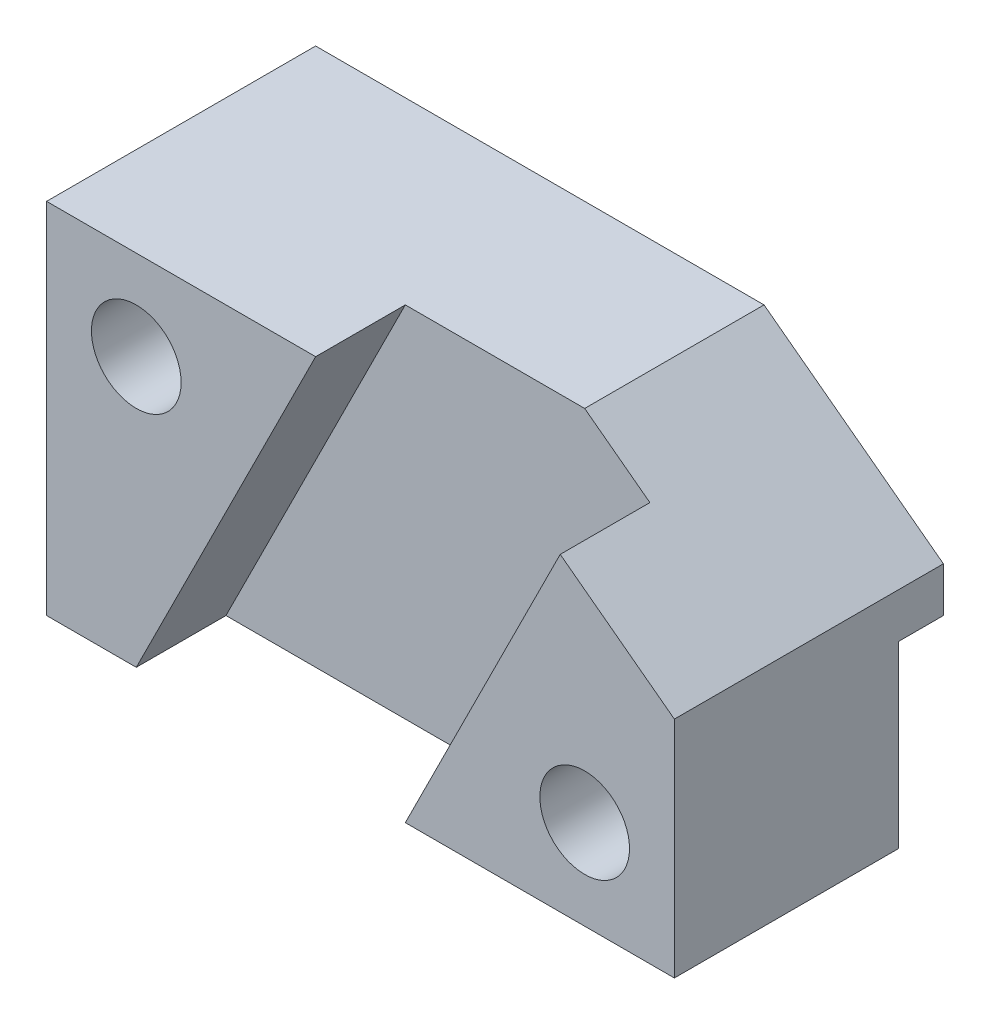
from build123d import *

# Parameters (mm, degrees)
SKETCH1_W               = 70
SKETCH1_H               = 30
BOSS_EXTRUDE1_DEPTH     = 40
CUT_EXTRUDE1_DEPTH      = 10
CUT_EXTRUDE2_DEPTH      = 1
CUT_EXTRUDE2_DEPTH_BACK = 31
SKETCH4_W               = 5
SKETCH4_H               = 20
CUT_EXTRUDE3_DEPTH      = 71
SKETCH5_R               = 5
CUT_EXTRUDE4_DEPTH      = 31
SKETCH6_R               = 5
CUT_EXTRUDE5_DEPTH      = 31


with BuildPart() as part:
    # Sketch1 → Boss-Extrude1 (new body)
    with BuildSketch(Plane(origin=(0, 0, 0), x_dir=(1, 0, 0), z_dir=(0, 1, 0))):
        with Locations((35, 15)):
            Rectangle(SKETCH1_W, SKETCH1_H)
    extrude(amount=BOSS_EXTRUDE1_DEPTH)

    # Sketch2 → Cut-Extrude1 (cut)
    with BuildSketch(Plane.XY):
        Polygon((30, 40), (10, 0), (40, 0), (60, 40), align=None)
    extrude(amount=-CUT_EXTRUDE1_DEPTH, mode=Mode.SUBTRACT)

    # Sketch3 → Cut-Extrude2 (cut, two sides)
    with BuildSketch(Plane(origin=(0, 0, -30), x_dir=(-1, 0, 0), z_dir=(0, 0, -1))) as cut_extrude2_sk:
        Polygon((-70, 40), (-70, 25), (-50, 40), align=None)
    extrude(amount=CUT_EXTRUDE2_DEPTH, mode=Mode.SUBTRACT)
    extrude(cut_extrude2_sk.sketch, amount=-CUT_EXTRUDE2_DEPTH_BACK, mode=Mode.SUBTRACT)

    # Sketch4 → Cut-Extrude3 (cut, through all)
    with BuildSketch(Plane(origin=(70, 0, 0), x_dir=(0, 0, -1), z_dir=(1, 0, 0))):
        with Locations((27.5, 10)):
            Rectangle(SKETCH4_W, SKETCH4_H)
    extrude(amount=-CUT_EXTRUDE3_DEPTH, mode=Mode.SUBTRACT)

    # Sketch5 → Cut-Extrude4 (cut, through all)
    with BuildSketch(Plane.XY):
        with Locations((60, 10)):
            Circle(SKETCH5_R)
    extrude(amount=-CUT_EXTRUDE4_DEPTH, mode=Mode.SUBTRACT)

    # Sketch6 → Cut-Extrude5 (cut, through all)
    with BuildSketch(Plane.XY):
        with Locations((10, 30)):
            Circle(SKETCH6_R)
    extrude(amount=-CUT_EXTRUDE5_DEPTH, mode=Mode.SUBTRACT)


solid = part.part
